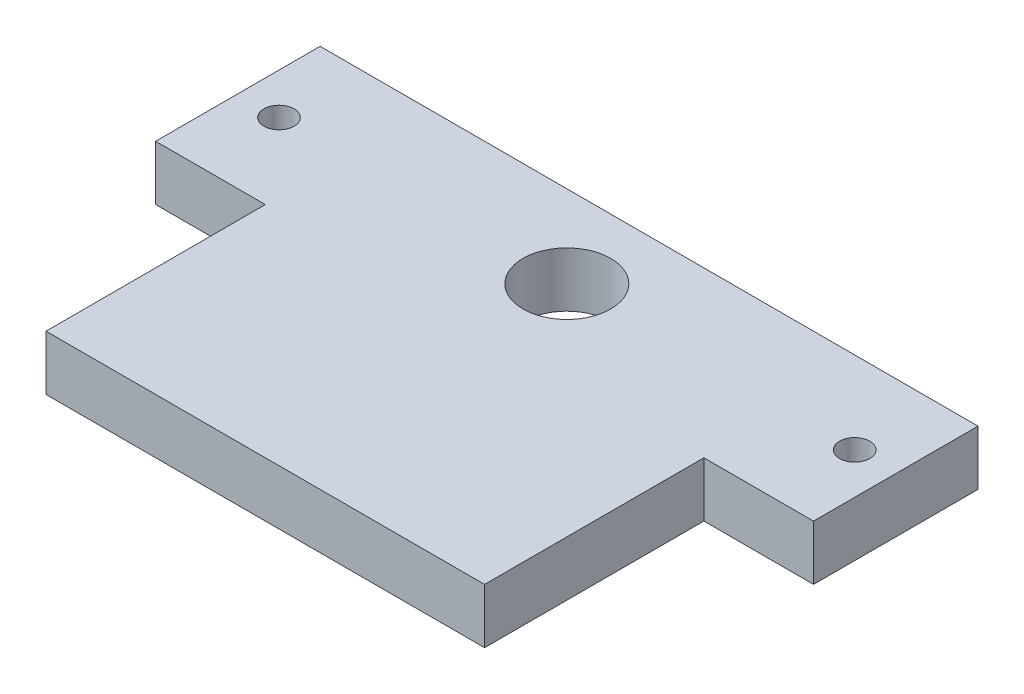
from build123d import *

# Parameters (mm, degrees)
SHUTTLE_W                = 6.096
SHUTTLE_H                = 1.524
SHUTTLE_EXTR_DEPTH       = 0.508
ELEC_BOUNDING_W          = 4.064
ELEC_BOUNDING_H          = 2.032
ELEC_BOUNDING_EXTR_DEPTH = 0.508
DRIVE_SCREW_R            = 0.4064
DRIVE_SCREW_EXTR_DEPTH   = 0.508
GUIDE_HOLES_R            = 0.1397
GUIDE_HOLES_EXTR_DEPTH   = 0.508


with BuildPart() as part:
    # shuttle → shuttle_extr (new body)
    with BuildSketch(Plane(origin=(0, 0, 0), x_dir=(1, 0, 0), z_dir=(0, 1, 0))):
        with Locations((-20.766651572, 3.215704526)):
            Rectangle(SHUTTLE_W, SHUTTLE_H)
    extrude(amount=-SHUTTLE_EXTR_DEPTH)

    # elec_bounding → elec_bounding_extr (add)
    with BuildSketch(Plane(origin=(0, 0, 0), x_dir=(1, 0, 0), z_dir=(0, 1, 0))):
        with Locations((-20.766651572, 1.437704526)):
            Rectangle(ELEC_BOUNDING_W, ELEC_BOUNDING_H)
    extrude(amount=-ELEC_BOUNDING_EXTR_DEPTH)

    # drive_screw → drive_screw_extr (cut)
    with BuildSketch(Plane(origin=(0, 0, 0), x_dir=(1, 0, 0), z_dir=(0, 1, 0))):
        with Locations((-20.766651572, 3.215704526)):
            Circle(DRIVE_SCREW_R)
    extrude(amount=-DRIVE_SCREW_EXTR_DEPTH, mode=Mode.SUBTRACT)

    # guide_holes → guide_holes_extr (cut)
    with BuildSketch(Plane(origin=(0, 0, 0), x_dir=(1, 0, 0), z_dir=(0, 1, 0))):
        with Locations((-23.433651572, 3.215704526)):
            Circle(GUIDE_HOLES_R)
        with Locations((-18.099651572, 3.215704526)):
            Circle(GUIDE_HOLES_R)
    extrude(amount=-GUIDE_HOLES_EXTR_DEPTH, mode=Mode.SUBTRACT)


solid = part.part
